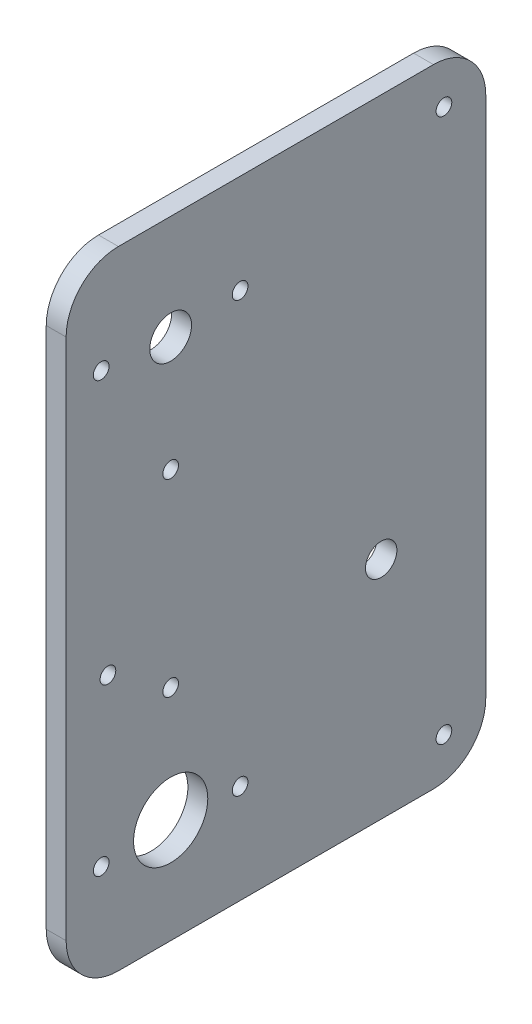
from build123d import *

# Parameters (mm, degrees)
SKETCH1_W           = 80.27017547
SKETCH1_H           = 120
SKETCH1_R           = 4
SKETCH1_R_2         = 7.1
SKETCH1_R_3         = 3
SKETCH1_R_4         = 1.5
BOSS_EXTRUDE1_DEPTH = 3.8
FILLET1_R           = 10


with BuildPart() as part:
    # Sketch1 → Boss-Extrude1 (new body)
    with BuildSketch(Plane(origin=(0, 0, 0), x_dir=(0, 0, -1), z_dir=(1, 0, 0))):
        with Locations((22.195139842, -58.413555688)):
            Rectangle(SKETCH1_W, SKETCH1_H)
        with Locations((2.060052107, -18.413555688)):
            Circle(SKETCH1_R, mode=Mode.SUBTRACT)
        with Locations((2.060052107, -98.413555688)):
            Circle(SKETCH1_R_2, mode=Mode.SUBTRACT)
        with Locations((42.330227577, -75.364196313)):
            Circle(SKETCH1_R_3, mode=Mode.SUBTRACT)
        with Locations((54.330227577, -6.413555688)):
            Circle(SKETCH1_R_4, mode=Mode.SUBTRACT)
        with Locations((54.330227577, -110.413555688)):
            Circle(SKETCH1_R_4, mode=Mode.SUBTRACT)
        with Locations((-9.939947893, -68.413555688)):
            Circle(SKETCH1_R_4, mode=Mode.SUBTRACT)
        with Locations((2.060052107, -76.472881174)):
            Circle(SKETCH1_R_4, mode=Mode.SUBTRACT)
        with Locations((-11.225361719, -99.483892921)):
            Circle(SKETCH1_R_4, mode=Mode.SUBTRACT)
        with Locations((15.345465933, -99.483892921)):
            Circle(SKETCH1_R_4, mode=Mode.SUBTRACT)
        with Locations((15.345465933, -17.343218455)):
            Circle(SKETCH1_R_4, mode=Mode.SUBTRACT)
        with Locations((2.060052107, -40.354230201)):
            Circle(SKETCH1_R_4, mode=Mode.SUBTRACT)
        with Locations((-11.225361719, -17.343218455)):
            Circle(SKETCH1_R_4, mode=Mode.SUBTRACT)
    extrude(amount=BOSS_EXTRUDE1_DEPTH)

    # Fillet1
    fillet1_edges = [part.edges().sort_by_distance(p)[0] for p in [
        (1.9, 1.586444312, 17.939947893),
        (1.9, 1.586444312, -62.330227577),
        (1.9, -118.413555688, -62.330227577),
        (1.9, -118.413555688, 17.939947893),
    ]]
    fillet(fillet1_edges, radius=FILLET1_R)


solid = part.part
